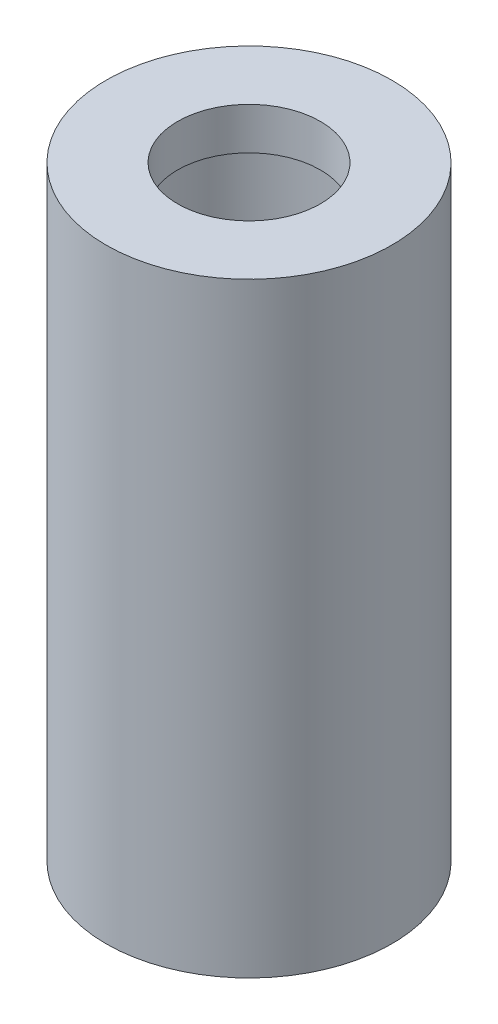
from build123d import *

# Parameters (mm, degrees)
SKETCH3_R          = 2.032
CUT_EXTRUDE1_DEPTH = 5.318


with BuildPart() as part:
    # Sketch2 → Revolve1 (revolve)
    with BuildSketch(Plane.XY):
        Polygon((3.175, 0), (4.318, 0), (4.318, 18.288), (2.159, 18.288), (2.159, 17.018), (2.921, 17.018), (2.921, 12.7), (3.175, 12.7), align=None)
    revolve(axis=Axis((0, 0, 0), (0, 1, 0)))

    # Sketch3 → Cut-Extrude1 (cut, through all)
    with BuildSketch(Plane.XY):
        with Locations((0, 8.128)):
            Circle(SKETCH3_R)
    extrude(amount=-CUT_EXTRUDE1_DEPTH, mode=Mode.SUBTRACT)


solid = part.part
